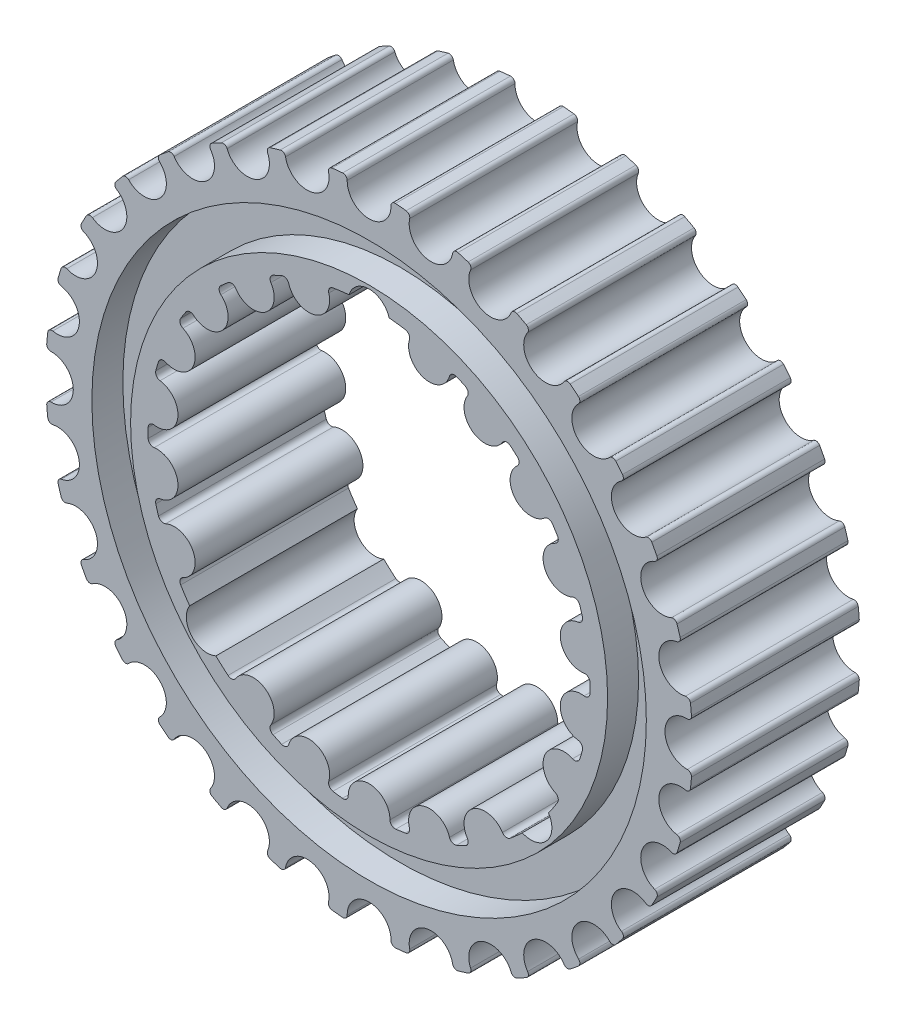
from build123d import *

# Parameters (mm, degrees)
BOSS_EXTRUDE1_DEPTH = 10.31875
CIRPATTERN2_COUNT   = 22
BOSS_EXTRUDE3_DEPTH = 10.31875
CIRPATTERN3_COUNT   = 32
SKETCH7_R           = 34.097455204
SKETCH7_R_2         = 29.334955204
CUT_EXTRUDE2_DEPTH  = 3.81
CUT_EXTRUDE3_START  = -21.6375
CUT_EXTRUDE3_DEPTH  = 22.6375
CIRPATTERN9_COUNT   = 11


with BuildPart() as part:
    # Sketch1 → Boss-Extrude1 (new body, symmetric)
    with BuildSketch(Plane.XY):
        with BuildLine():
            Line((-3.86769036, 26.900377326), (-3.986424042, 27.726188223))
            ThreePointArc((-3.986424042, 27.726188223), (0, 28.011302897), (3.986424042, 27.726188223))
            Line((3.986424042, 27.726188223), (3.86769036, 26.900377326))
            ThreePointArc((3.86769036, 26.900377326), (3.576738275, 26.940606384), (3.285368406, 26.977688623))
            ThreePointArc((3.285368406, 26.977688623), (2.78430595, 26.82181218), (2.568599499, 26.343448535))
            ThreePointArc((2.568599499, 26.343448535), (0, 23.777), (-2.568599499, 26.343448535))
            ThreePointArc((-2.568599499, 26.343448535), (-2.78430595, 26.82181218), (-3.285368406, 26.977688623))
            ThreePointArc((-3.285368406, 26.977688623), (-3.576738275, 26.940606384), (-3.86769036, 26.900377326))
        make_face()
    boss_extrude1 = extrude(amount=BOSS_EXTRUDE1_DEPTH, both=True)

    # CirPattern2: Boss-Extrude1 ×22 about axis
    cirpattern2_axis = Axis((0, 0, 0), (0, 0, 1))
    for i in range(1, CIRPATTERN2_COUNT):
        add(boss_extrude1.rotate(cirpattern2_axis, i * 360 / CIRPATTERN2_COUNT))

    # Sketch4 → Boss-Extrude3 (add, symmetric)
    with BuildSketch(Plane.XY):
        with BuildLine():
            Line((-3.899358104, 39.590847228), (-2.745587807, 27.876420818))
            ThreePointArc((-2.745587807, 27.876420818), (0, 28.011302897), (2.745587807, 27.876420818))
            Line((2.745587807, 27.876420818), (3.899358104, 39.590847228))
            ThreePointArc((3.899358104, 39.590847228), (3.574473478, 39.621500694), (3.24934834, 39.649488184))
            ThreePointArc((3.24934834, 39.649488184), (2.856685784, 39.512307537), (2.695117452, 39.129034674))
            ThreePointArc((2.695117452, 39.129034674), (0, 36.382410408), (-2.695117452, 39.129034674))
            ThreePointArc((-2.695117452, 39.129034674), (-2.856685784, 39.512307537), (-3.24934834, 39.649488184))
            ThreePointArc((-3.24934834, 39.649488184), (-3.574473478, 39.621500694), (-3.899358104, 39.590847228))
        make_face()
    boss_extrude3 = extrude(amount=BOSS_EXTRUDE3_DEPTH, both=True)

    # CirPattern3: Boss-Extrude3 ×32 about axis
    cirpattern3_axis = Axis((0, 0, 0), (0, 0, 1))
    for i in range(1, CIRPATTERN3_COUNT):
        add(boss_extrude3.rotate(cirpattern3_axis, i * 360 / CIRPATTERN3_COUNT))

    # Sketch7 → Cut-Extrude2 (cut)
    with BuildSketch(Plane.XY.offset(10.31875)):
        Circle(SKETCH7_R)
        Circle(SKETCH7_R_2, mode=Mode.SUBTRACT)
    extrude(amount=-CUT_EXTRUDE2_DEPTH, mode=Mode.SUBTRACT)

    # Sketch11 → Cut-Extrude3 (cut)
    with BuildSketch(Plane.XY.offset(10.31875).offset(CUT_EXTRUDE3_START)):
        with BuildLine():
            ThreePointArc((3.285368406, 26.977688623), (2.78430595, 26.82181218), (2.568599499, 26.343448535))
            ThreePointArc((2.568599499, 26.343448535), (0, 23.777), (-2.568599499, 26.343448535))
            ThreePointArc((-2.568599499, 26.343448535), (-2.78430595, 26.82181218), (-3.285368406, 26.977688623))
            ThreePointArc((-3.285368406, 26.977688623), (-2.875929125, 27.024403058), (-2.465828586, 27.064903813))
            ThreePointArc((-2.465828586, 27.064903813), (0, 28.9142008), (2.465828586, 27.064903813))
            ThreePointArc((2.465828586, 27.064903813), (2.875929125, 27.024403058), (3.285368406, 26.977688623))
        make_face()
    cut_extrude3 = extrude(amount=CUT_EXTRUDE3_DEPTH, mode=Mode.SUBTRACT)

    # CirPattern9: Cut-Extrude3 ×11 about axis, 8 skipped
    cirpattern9_axis = Axis((0, 0, 11.350625), (0, 0, -1))
    add([cut_extrude3.rotate(cirpattern9_axis, i * 360 / CIRPATTERN9_COUNT) for i in range(1, CIRPATTERN9_COUNT) if i not in (1, 2, 3, 5, 6, 8, 9, 10)], mode=Mode.SUBTRACT)


solid = part.part
